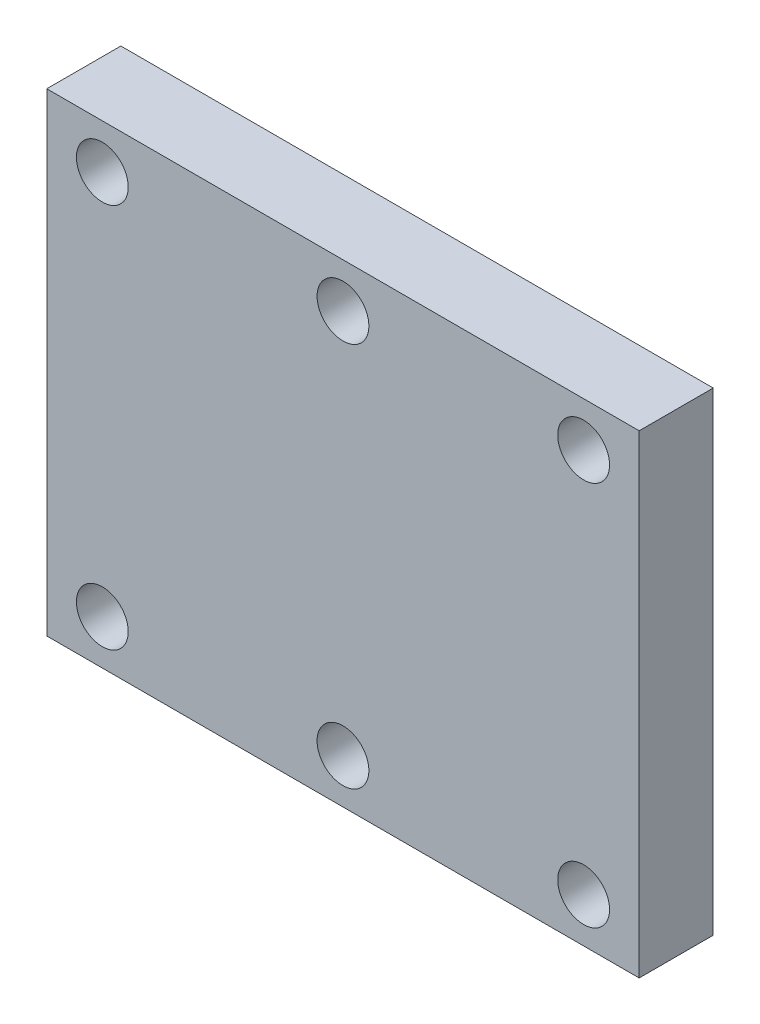
from build123d import *

# Parameters (mm, degrees)
SKETCH1_W            = 80
SKETCH1_H            = 64
BOSS_EXTRUDE1_DEPTH  = 10
LPATTERN1_COUNT      = 3
LPATTERN1_PITCH      = 32.5
LPATTERN1_COUNT_DIR2 = 2
LPATTERN1_PITCH_DIR2 = 52


with BuildPart() as part:
    # Sketch1 → Boss-Extrude1 (new body)
    with BuildSketch(Plane.XY):
        with Locations((40, 0)):
            Rectangle(SKETCH1_W, SKETCH1_H)
    extrude(amount=BOSS_EXTRUDE1_DEPTH)

    # Sketch4 → Ø7.0 (7) Diameter Hole1 (revolve, cut)
    with BuildSketch(Plane(origin=(7.5, -26, 10), x_dir=(0, -1, 0), z_dir=(1, 0, 0))):
        Polygon((0, 0), (0, 28.103012167), (3.5, 26), (3.5, 0), align=None)
    f_7_0_7_diameter_hole1 = revolve(axis=Axis((7.5, -26, 16.35), (0, 0, -1)), mode=Mode.SUBTRACT)

    # LPattern1: 7.0 _7_ Diameter Hole1 3 × 2
    with Locations(*[(i * LPATTERN1_PITCH, j * LPATTERN1_PITCH_DIR2, 0) for i in range(LPATTERN1_COUNT) for j in range(LPATTERN1_COUNT_DIR2) if (i, j) != (0, 0)]):
        add(f_7_0_7_diameter_hole1, mode=Mode.SUBTRACT)


solid = part.part
